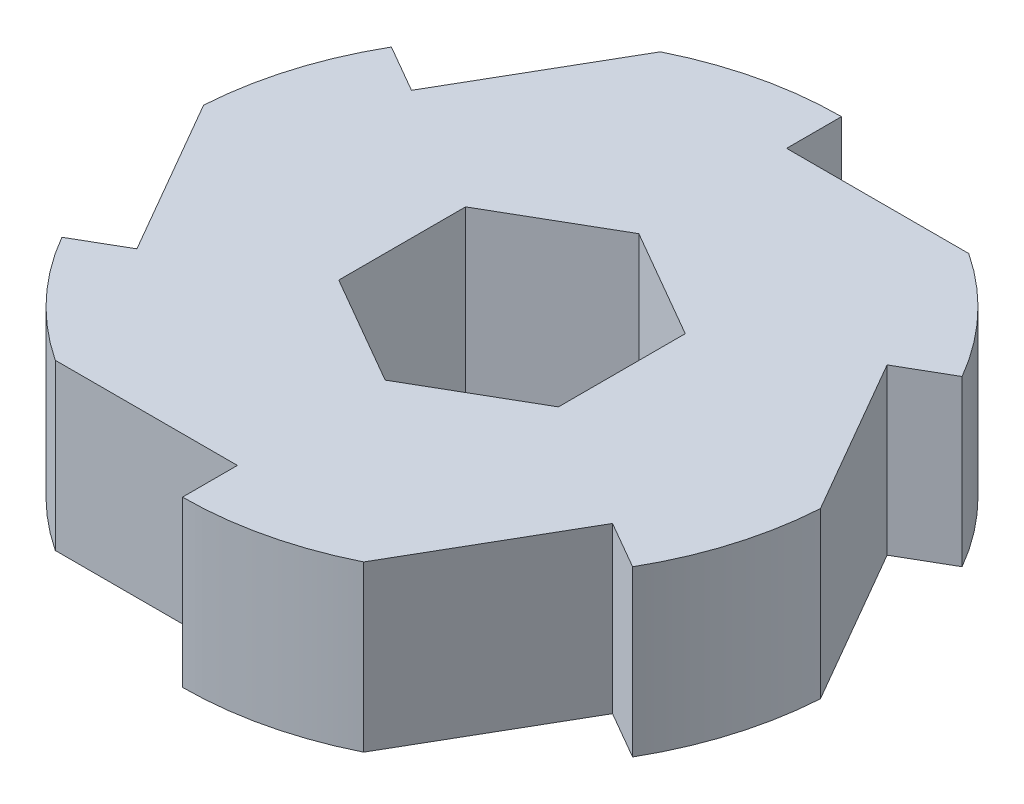
from build123d import *

# Parameters (mm, degrees)
SKETCH2_R           = 19.05
BOSS_EXTRUDE2_DEPTH = 9.525
CUT_EXTRUDE1_START  = -10.525
CUT_EXTRUDE1_DEPTH  = 11.525
CIRPATTERN1_COUNT   = 6
CUT_EXTRUDE2_DEPTH  = 10.525


with BuildPart() as part:
    # Sketch2 → Boss-Extrude2 (new body)
    with BuildSketch(Plane(origin=(0, 0, 0), x_dir=(1, 0, 0), z_dir=(0, 1, 0))):
        Circle(SKETCH2_R)
    extrude(amount=BOSS_EXTRUDE2_DEPTH)

    # Sketch3 → Cut-Extrude1 (cut)
    with BuildSketch(Plane(origin=(0, 9.525, 0), x_dir=(1, 0, 0), z_dir=(0, 1, 0)).offset(CUT_EXTRUDE1_START)):
        Polygon((0, 120.586851799), (0, 19.05), (0, 15.875), (10.530283709, 15.875), (112.067135509, 15.875), (250.709992792, 164.25655956), (138.642857283, 268.96841136), align=None)
    cut_extrude1 = extrude(amount=CUT_EXTRUDE1_DEPTH, mode=Mode.SUBTRACT)

    # CirPattern1: Cut-Extrude1 ×6 about axis
    cirpattern1_axis = Axis((0, 9.525, 0), (0, -1, 0))
    for i in range(1, CIRPATTERN1_COUNT):
        add(cut_extrude1.rotate(cirpattern1_axis, i * 360 / CIRPATTERN1_COUNT), mode=Mode.SUBTRACT)

    # Sketch4 → Cut-Extrude2 (cut, through all)
    with BuildSketch(Plane(origin=(0, 9.525, 0), x_dir=(1, 0, 0), z_dir=(0, 1, 0))):
        Polygon((0, 7.332348419), (-6.35, 3.666174209), (-6.35, -3.666174209), (0, -7.332348419), (6.35, -3.666174209), (6.35, 3.666174209), align=None)
    extrude(amount=-CUT_EXTRUDE2_DEPTH, mode=Mode.SUBTRACT)


solid = part.part
